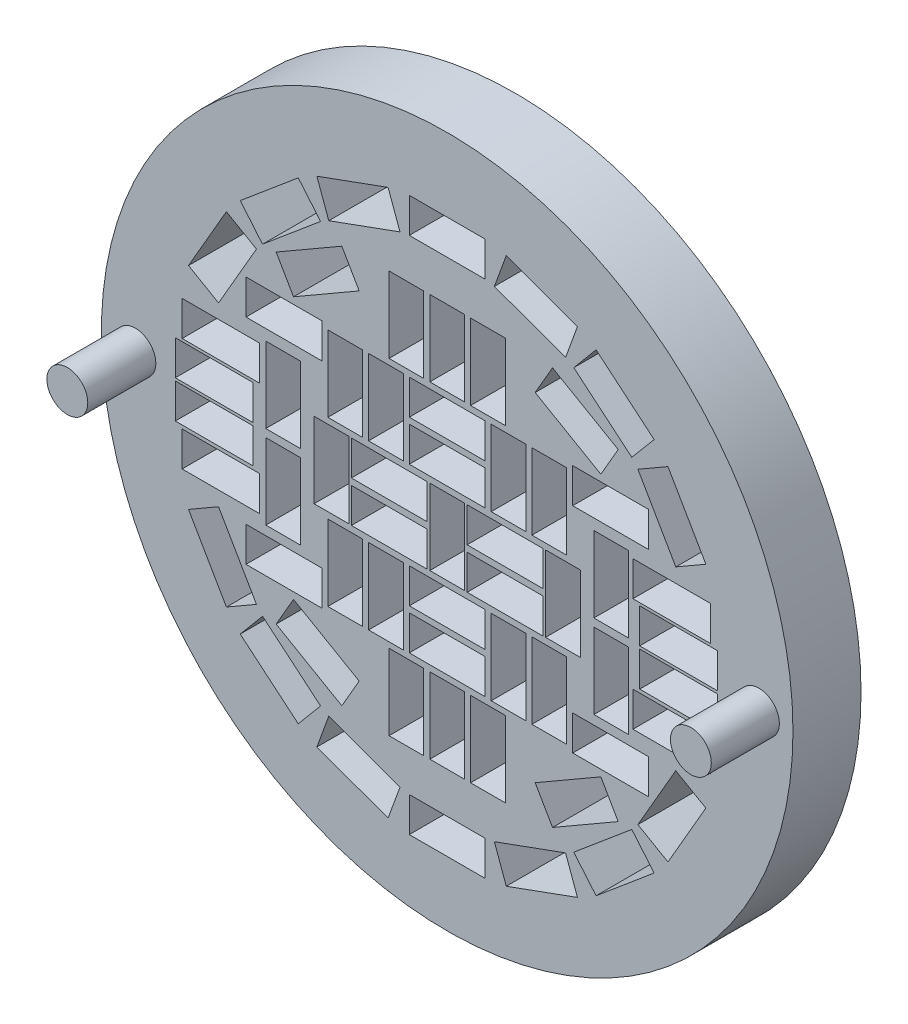
from build123d import *

# Parameters (mm, degrees)
ESQUISSE1_R             = 25.4
BOSS_EXTRU_1_DEPTH      = 5
ESQUISSE2_W             = 5.565
ESQUISSE2_H             = 2.55
ESQUISSE2_W_2           = 2.55
ESQUISSE2_H_2           = 5.565
ENL_V_MAT_EXTRU_1_DEPTH = 6
ESQUISSE3_W             = 5.7
ESQUISSE3_H             = 2.55
ENL_V_MAT_EXTRU_2_DEPTH = 6
ESQUISSE4_W             = 5.57
ESQUISSE4_H             = 2.55
ENL_V_MAT_EXTRU_3_DEPTH = 6
ESQUISSE5_R             = 1.5
BOSS_EXTRU_2_DEPTH      = 5


with BuildPart() as part:
    # Esquisse1 → Boss.-Extru.1 (new body)
    with BuildSketch(Plane.XY):
        with Locations((16.625210007, 7.108710486)):
            Circle(ESQUISSE1_R)
    extrude(amount=BOSS_EXTRU_1_DEPTH)

    # Esquisse2 → Enlèv. mat.-Extru.1 (cut, through all)
    with BuildSketch(Plane.XY.offset(5)):
        with Locations((12.372710007, 8.28394281)):
            Rectangle(ESQUISSE2_W, ESQUISSE2_H)
        with Locations((25.125210007, 6.784746769)):
            Rectangle(ESQUISSE2_W_2, ESQUISSE2_H_2)
        with Locations((16.625210007, 6.784746769)):
            Rectangle(ESQUISSE2_W_2, ESQUISSE2_H_2)
        with Locations((16.625210007, 18.784746769)):
            Rectangle(ESQUISSE2_W_2, ESQUISSE2_H_2)
        with Locations((8.125210007, 6.784746769)):
            Rectangle(ESQUISSE2_W_2, ESQUISSE2_H_2)
        with Locations((16.625210007, -5.215253231)):
            Rectangle(ESQUISSE2_W_2, ESQUISSE2_H_2)
        with Locations((20.872710007, 8.28394281)):
            Rectangle(ESQUISSE2_W, ESQUISSE2_H)
        with Locations((12.372710007, 5.26394281)):
            Rectangle(ESQUISSE2_W, ESQUISSE2_H)
        with Locations((20.872710007, 5.26394281)):
            Rectangle(ESQUISSE2_W, ESQUISSE2_H)
        with Locations((16.625210007, 2.278246769)):
            Rectangle(ESQUISSE2_W, ESQUISSE2_H)
        with Locations((16.625210007, 11.285246769)):
            Rectangle(ESQUISSE2_W, ESQUISSE2_H)
        with Locations((16.625210007, 14.278246769)):
            Rectangle(ESQUISSE2_W, ESQUISSE2_H)
        with Locations((16.625210007, -0.714753231)):
            Rectangle(ESQUISSE2_W, ESQUISSE2_H)
        with Locations((12.124710007, 12.784746769)):
            Rectangle(ESQUISSE2_W_2, ESQUISSE2_H_2)
        with Locations((9.134710007, 12.784746769)):
            Rectangle(ESQUISSE2_W_2, ESQUISSE2_H_2)
        with Locations((21.134710007, 12.784746769)):
            Rectangle(ESQUISSE2_W_2, ESQUISSE2_H_2)
        with Locations((24.124710007, 12.784746769)):
            Rectangle(ESQUISSE2_W_2, ESQUISSE2_H_2)
        with Locations((21.134710007, 0.754746769)):
            Rectangle(ESQUISSE2_W_2, ESQUISSE2_H_2)
        with Locations((24.124710007, 0.754746769)):
            Rectangle(ESQUISSE2_W_2, ESQUISSE2_H_2)
        with Locations((9.134710007, 0.754746769)):
            Rectangle(ESQUISSE2_W_2, ESQUISSE2_H_2)
        with Locations((12.124710007, 0.754746769)):
            Rectangle(ESQUISSE2_W_2, ESQUISSE2_H_2)
        Polygon((25.321877923, 22.543159749), (26.194029289, 24.939375932), (20.964639854, 26.84271803), (20.092488489, 24.446501847), align=None)
        with Locations((16.625210007, 25.842246769)):
            Rectangle(ESQUISSE2_W, ESQUISSE2_H)
        Polygon((30.18709934, 18.618375555), (31.826207744, 20.571788884), (27.563170418, 24.148901932), (25.924062014, 22.195488602), align=None)
        Polygon((33.41655675, 13.266281083), (35.62492153, 14.541281083), (32.84242153, 19.360712455), (30.63405675, 18.085712455), align=None)
        Polygon((30.63405675, -4.516218917), (32.84242153, -5.791218917), (35.62492153, -0.971787545), (33.41655675, 0.303212455), align=None)
        Polygon((25.924062014, -8.625995065), (27.563170418, -10.579408395), (31.826207744, -7.002295347), (30.18709934, -5.048882017), align=None)
        Polygon((20.092488489, -10.877008309), (20.964639854, -13.273224492), (26.194029289, -11.369882395), (25.321877923, -8.973666212), align=None)
        with Locations((16.625210007, -12.272753231)):
            Rectangle(ESQUISSE2_W, ESQUISSE2_H)
        Polygon((7.928542091, -8.973666212), (7.056390726, -11.369882395), (12.285780161, -13.273224492), (13.157931526, -10.877008309), align=None)
        Polygon((3.063320675, -5.048882017), (1.424212271, -7.002295347), (5.687249596, -10.579408395), (7.326358001, -8.625995065), align=None)
        Polygon((-0.166136735, 0.303212455), (-2.374501515, -0.971787545), (0.407998485, -5.791218917), (2.616363265, -4.516218917), align=None)
        Polygon((2.616363265, 18.085712455), (0.407998485, 19.360712455), (-2.374501515, 14.541281083), (-0.166136735, 13.266281083), align=None)
        Polygon((7.326358001, 22.195488602), (5.687249596, 24.148901932), (1.424212271, 20.571788884), (3.063320675, 18.618375555), align=None)
        with Locations((13.628210007, 18.778746769)):
            Rectangle(ESQUISSE2_W_2, ESQUISSE2_H_2)
        with Locations((19.618210007, 18.778746769)):
            Rectangle(ESQUISSE2_W_2, ESQUISSE2_H_2)
        with Locations((13.628210007, -5.221253231)):
            Rectangle(ESQUISSE2_W_2, ESQUISSE2_H_2)
        with Locations((19.618210007, -5.221253231)):
            Rectangle(ESQUISSE2_W_2, ESQUISSE2_H_2)
        with Locations((4.575210007, 9.79144281)):
            Rectangle(ESQUISSE2_W_2, ESQUISSE2_H_2)
        with Locations((28.675210007, 9.79144281)):
            Rectangle(ESQUISSE2_W_2, ESQUISSE2_H_2)
        with Locations((4.575210007, 3.65144281)):
            Rectangle(ESQUISSE2_W_2, ESQUISSE2_H_2)
        with Locations((28.675210007, 3.65144281)):
            Rectangle(ESQUISSE2_W_2, ESQUISSE2_H_2)
        Polygon((13.157931526, 24.446501847), (12.285780161, 26.84271803), (7.056390726, 24.939375932), (7.928542091, 22.543159749), align=None)
    extrude(amount=-ENL_V_MAT_EXTRU_1_DEPTH, mode=Mode.SUBTRACT)

    # Esquisse3 → Enlèv. mat.-Extru.2 (cut, through all)
    with BuildSketch(Plane.XY.offset(5)):
        with Locations((0.007210007, 10.942246769)):
            Rectangle(ESQUISSE3_W, ESQUISSE3_H)
        with Locations((33.117210007, 10.942246769)):
            Rectangle(ESQUISSE3_W, ESQUISSE3_H)
        with Locations((33.117210007, 2.642246769)):
            Rectangle(ESQUISSE3_W, ESQUISSE3_H)
        with Locations((0.007210007, 2.642246769)):
            Rectangle(ESQUISSE3_W, ESQUISSE3_H)
        with Locations((33.617210007, 8.192246769)):
            Rectangle(ESQUISSE3_W, ESQUISSE3_H)
        with Locations((-0.492789993, 8.192246769)):
            Rectangle(ESQUISSE3_W, ESQUISSE3_H)
        with Locations((33.617210007, 5.442246769)):
            Rectangle(ESQUISSE3_W, ESQUISSE3_H)
        with Locations((-0.492789993, 5.442246769)):
            Rectangle(ESQUISSE3_W, ESQUISSE3_H)
    extrude(amount=-ENL_V_MAT_EXTRU_2_DEPTH, mode=Mode.SUBTRACT)

    # Esquisse4 → Enlèv. mat.-Extru.3 (cut, through all)
    with BuildSketch(Plane.XY.offset(5)):
        with Locations((28.631710007, 14.64894281)):
            Rectangle(ESQUISSE4_W, ESQUISSE4_H)
        with Locations((4.631710007, 14.64894281)):
            Rectangle(ESQUISSE4_W, ESQUISSE4_H)
        with Locations((28.631710007, -1.08105719)):
            Rectangle(ESQUISSE4_W, ESQUISSE4_H)
        with Locations((4.631710007, -1.08105719)):
            Rectangle(ESQUISSE4_W, ESQUISSE4_H)
        Polygon((4.063320675, 18.618375555), (8.887082174, 21.403375555), (10.162082174, 19.195010775), (5.338320675, 16.410010775), align=None)
        Polygon((29.18709934, 18.618375555), (24.363337841, 21.403375555), (23.088337841, 19.195010775), (27.91209934, 16.410010775), align=None)
        Polygon((4.063320675, -5.048882017), (8.887082174, -7.833882017), (10.162082174, -5.625517237), (5.338320675, -2.840517237), align=None)
        Polygon((29.18709934, -5.048882017), (24.363337841, -7.833882017), (23.088337841, -5.625517237), (27.91209934, -2.840517237), align=None)
    extrude(amount=-ENL_V_MAT_EXTRU_3_DEPTH, mode=Mode.SUBTRACT)

    # Esquisse5 → Boss.-Extru.2 (add)
    with BuildSketch(Plane.XY.offset(5)):
        with Locations((-6.274789993, 7.108710486)):
            Circle(ESQUISSE5_R)
        with Locations((39.525210007, 7.108710486)):
            Circle(ESQUISSE5_R)
    extrude(amount=BOSS_EXTRU_2_DEPTH)


solid = part.part
